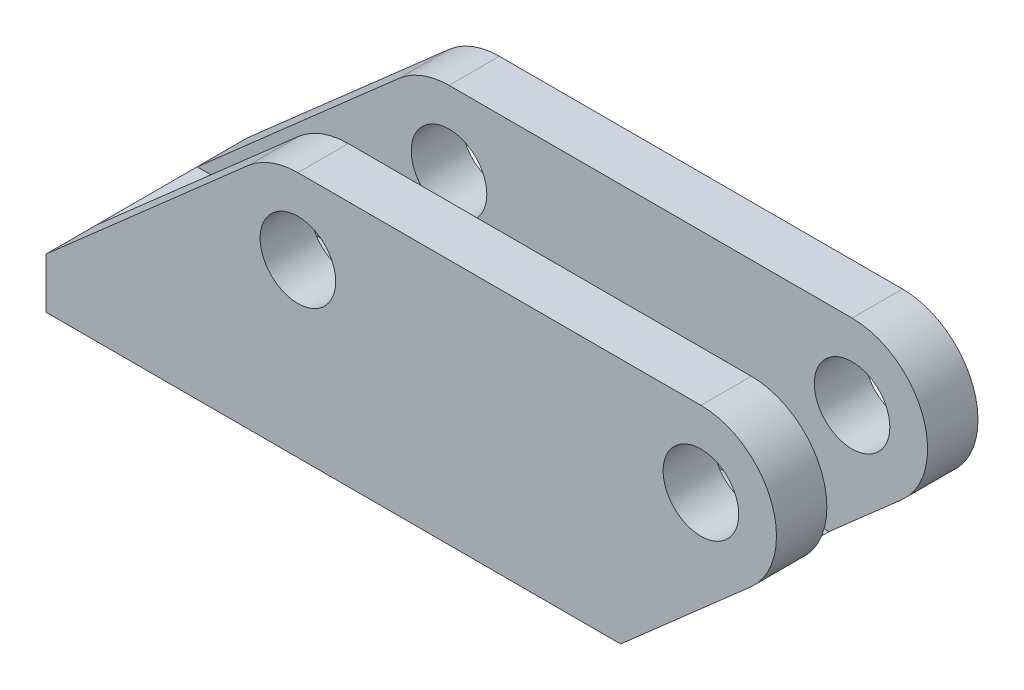
from build123d import *

# Parameters (mm, degrees)
SKETCH1_R           = 4.7625
BOSS_EXTRUDE1_DEPTH = 25.4
SKETCH2_R           = 3.175
CUT_EXTRUDE1_DEPTH  = 32.115
SKETCH3_W           = 12.7
SKETCH3_H           = 28.80549591
CUT_EXTRUDE2_DEPTH  = 93.075


with BuildPart() as part:
    # Sketch1 → Boss-Extrude1 (new body)
    with BuildSketch(Plane.XY):
        with BuildLine():
            Line((50.8, 15.875), (0, 15.875))
            ThreePointArc((0, 15.875), (-3.361595996, 15.262087149), (-6.29056934, 13.502227791))
            Line((-6.29056934, 13.502227791), (-31.75, -8.89))
            Line((-31.75, -8.89), (-31.75, -15.24))
            Line((-31.75, -15.24), (40.675165573, -15.24))
            Line((40.675165573, -15.24), (57.09056934, -0.802227791))
            ThreePointArc((57.09056934, -0.802227791), (59.712087149, 9.711595996), (50.8, 15.875))
        make_face()
        with Locations((0, 6.35)):
            Circle(SKETCH1_R, mode=Mode.SUBTRACT)
        with Locations((50.8, 6.35)):
            Circle(SKETCH1_R, mode=Mode.SUBTRACT)
    extrude(amount=BOSS_EXTRUDE1_DEPTH)

    # Sketch2 → Cut-Extrude1 (cut, through all)
    with BuildSketch(Plane(origin=(0, -15.24, 0), x_dir=(-1, 0, 0), z_dir=(0, -1, 0))):
        with Locations((-19.05, -12.7)):
            Circle(SKETCH2_R)
        with Locations((19.05, -12.7)):
            Circle(SKETCH2_R)
    extrude(amount=-CUT_EXTRUDE1_DEPTH, mode=Mode.SUBTRACT)

    # Sketch3 → Cut-Extrude2 (cut, through all)
    with BuildSketch(Plane.ZY.offset(31.75)):
        with Locations((12.7, 5.512747955)):
            Rectangle(SKETCH3_W, SKETCH3_H)
    extrude(amount=-CUT_EXTRUDE2_DEPTH, mode=Mode.SUBTRACT)


solid = part.part
